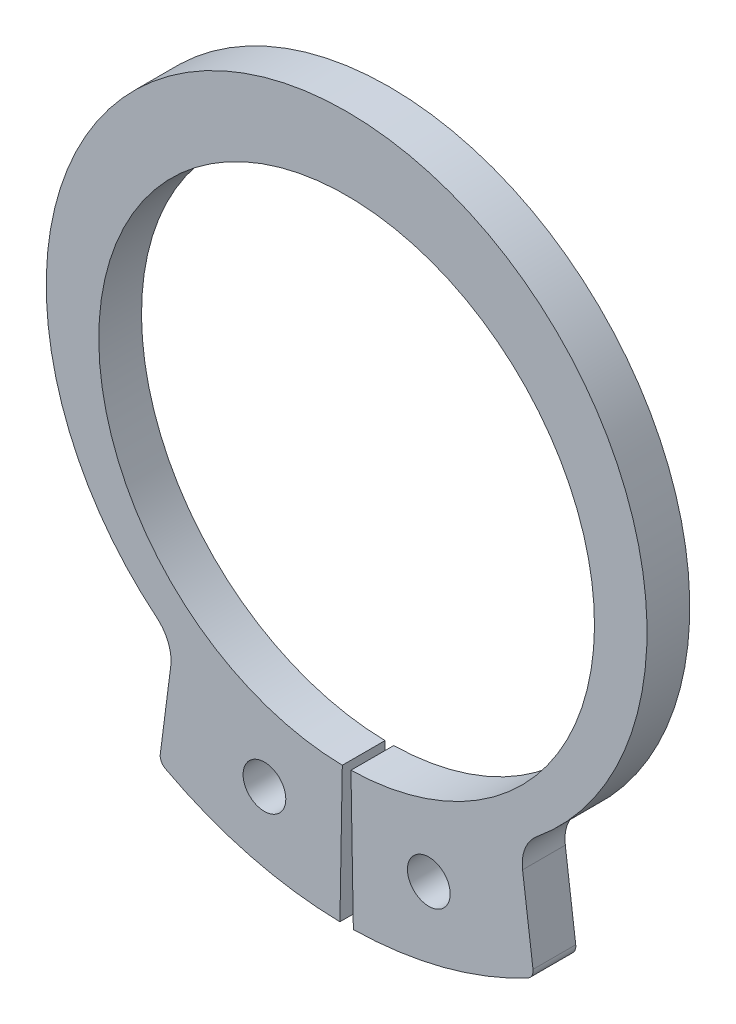
from build123d import *

# Parameters (mm, degrees)
SKETCH2_R           = 1
BOSS_EXTRUDE1_DEPTH = 1
FILLET1_R           = 1.861618014
FILLET2_R           = 0.465404504


with BuildPart() as part:
    # Sketch2 → Boss-Extrude1 (new body, symmetric)
    with BuildSketch(Plane.XY):
        with BuildLine():
            Line((-8.762233136, -15.726474067), (-8.096527006, -10.551599426))
            ThreePointArc((-8.096527006, -10.551599426), (-13.401846727, 5.188067163), (0, 15))
            Line((0, 15), (0, 11.6))
            ThreePointArc((0, 11.6), (-11.599558308, 0.101227812), (-0.202447915, -11.598233264))
            Line((-0.202447915, -11.598233264), (-0.314191169, -18))
            ThreePointArc((-0.314191169, -18), (-4.678418491, -17.384220331), (-8.762233136, -15.726474067))
        make_face()
        with Locations((-3.84647005, -14.292839124)):
            Circle(SKETCH2_R, mode=Mode.SUBTRACT)
    extrude(amount=BOSS_EXTRUDE1_DEPTH, both=True)

    # Fillet1
    fillet1_edges = [part.edges().sort_by_distance(p)[0] for p in [
        (-8.096527006, -10.551599426, 0),
    ]]
    fillet(fillet1_edges, radius=FILLET1_R)

    # Fillet2
    fillet2_edges = [part.edges().sort_by_distance(p)[0] for p in [
        (-8.762233136, -15.726474067, 0),
    ]]
    fillet(fillet2_edges, radius=FILLET2_R)

    # Mirror1: part across face


with BuildPart() as part_1:
    add(part.part)
    add(part.part.mirror(Plane(origin=(0, 13.3, 0), x_dir=(0, 0, 1), z_dir=(1, 0, 0))))


solid = part_1.part
